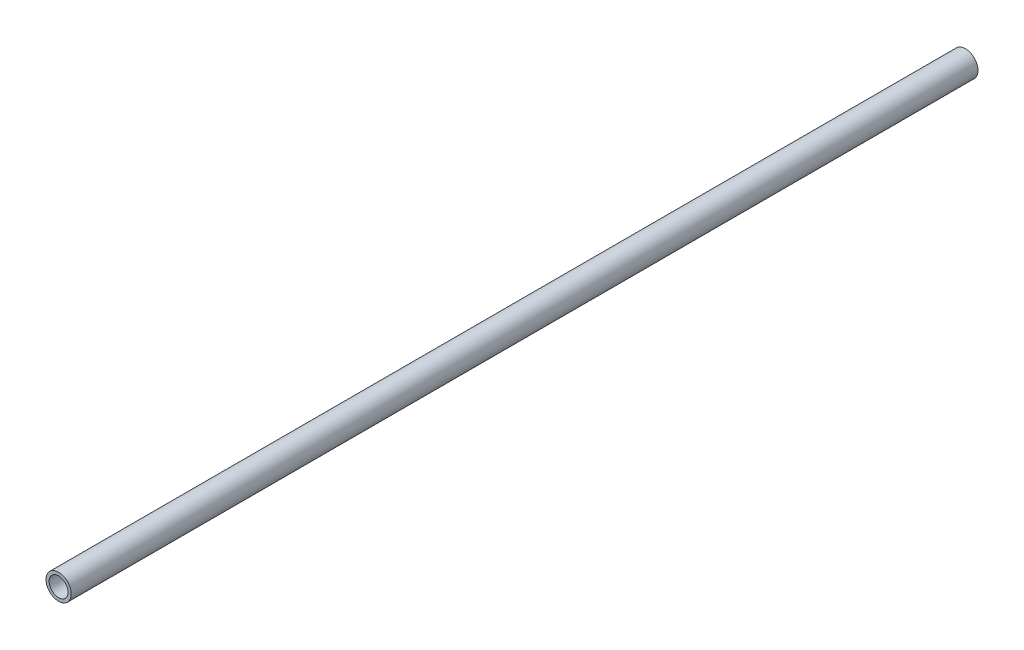
from build123d import *

# Parameters (mm, degrees)
SKETCH_1_R      = 8
SKETCH_1_R_2    = 6
EXTRUDE_1_DEPTH = 575


with BuildPart() as part:
    # 草图1 → 凸台-拉伸1 (new body)
    with BuildSketch(Plane.XY):
        Circle(SKETCH_1_R)
        Circle(SKETCH_1_R_2, mode=Mode.SUBTRACT)
    extrude(amount=EXTRUDE_1_DEPTH)


solid = part.part
